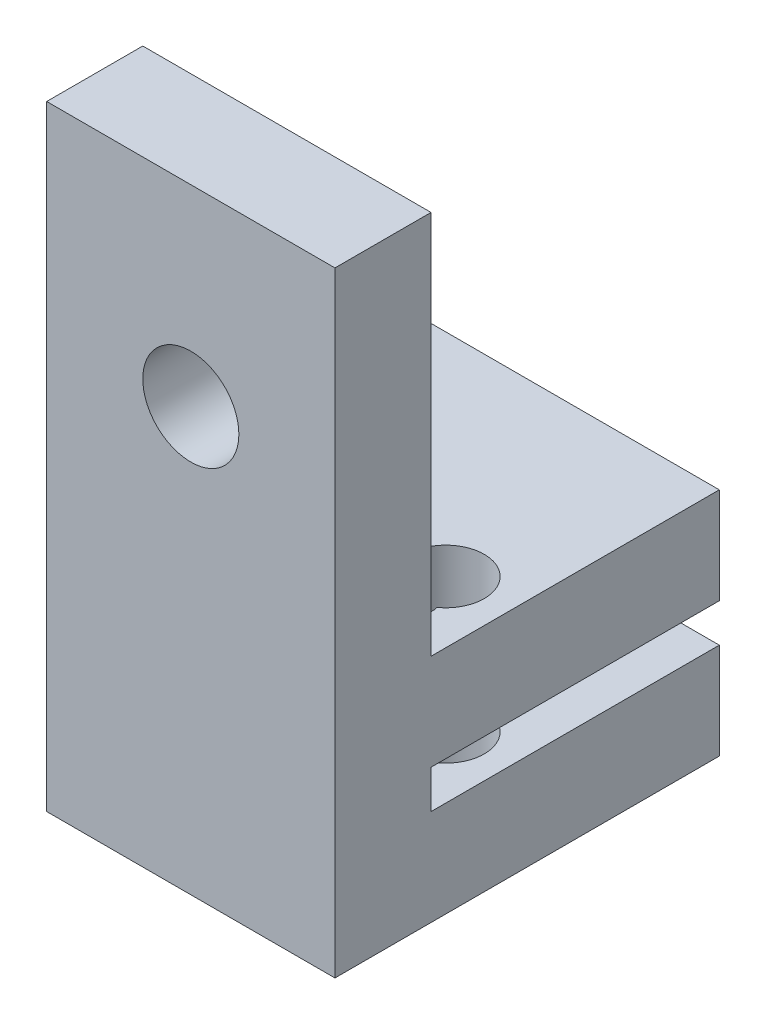
from build123d import *

# Parameters (mm, degrees)
ESTRUSIONE_ESTRUSIONE1_DEPTH = 15
SCHIZZO5_W                   = 15
SCHIZZO5_H                   = 20
SCHIZZO5_R                   = 2.5
ESTRUSIONE_ESTRUSIONE2_DEPTH = 5
SCHIZZO6_R                   = 2
TAGLIO_ESTRUSIONE2_DEPTH     = 12
SCHIZZO4_R                   = 1.5
TAGLIO_ESTRUSIONE1_DEPTH     = 12


with BuildPart() as part:
    # Schizzo1 → Estrusione-Estrusione1 (new body)
    with BuildSketch(Plane(origin=(0, 0, 0), x_dir=(0, 0, -1), z_dir=(1, 0, 0))):
        Polygon((0, 0), (-20, 0), (-20, 12), (0, 12), (0, 7), (-15, 7), (-15, 5), (0, 5), align=None)
    extrude(amount=ESTRUSIONE_ESTRUSIONE1_DEPTH)

    # Schizzo5 → Estrusione-Estrusione2 (add)
    with BuildSketch(Plane.XY.offset(20)):
        with Locations((7.5, 22)):
            Rectangle(SCHIZZO5_W, SCHIZZO5_H)
        with Locations((7.5, 22)):
            Circle(SCHIZZO5_R, mode=Mode.SUBTRACT)
    extrude(amount=-ESTRUSIONE_ESTRUSIONE2_DEPTH)

    # Schizzo6 → Taglio-Estrusione2 (cut)
    with BuildSketch(Plane.XZ):
        with Locations((3.21150116, 11.021600653)):
            Circle(SCHIZZO6_R)
        with Locations((11.78849884, 11.021600653)):
            Circle(SCHIZZO6_R)
    extrude(amount=-TAGLIO_ESTRUSIONE2_DEPTH, mode=Mode.SUBTRACT)

    # Schizzo4 → Taglio-Estrusione1 (cut)
    with BuildSketch(Plane.XZ):
        with Locations((3.5, 13)):
            Circle(SCHIZZO4_R)
        with Locations((11.5, 13)):
            Circle(SCHIZZO4_R)
    extrude(amount=-TAGLIO_ESTRUSIONE1_DEPTH, mode=Mode.SUBTRACT)


solid = part.part
